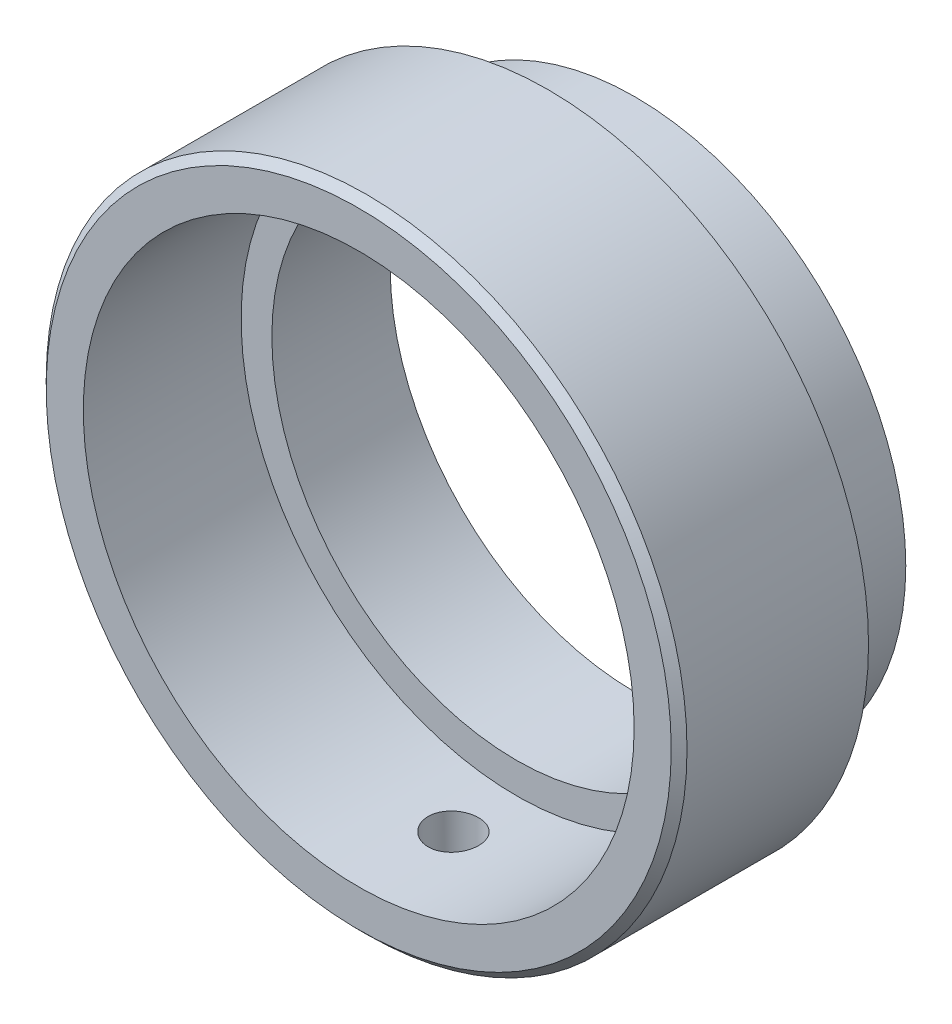
from build123d import *

# Parameters (mm, degrees)
SKETCH2_R          = 1.6
CUT_EXTRUDE1_DEPTH = 25


with BuildPart() as part:
    # Sketch1 → Revolve1 (revolve)
    with BuildSketch(Plane(origin=(0, 0, 0), x_dir=(1, 0, 0), z_dir=(0, 1, 0))):
        Polygon((-17.45, 0), (-19.8, 0), (-20.3, 0.5), (-20.3, 12), (-17.160824742, 12), (-17.160824742, 13.5), (-16.760824742, 13.5), (-16.760824742, 14), (-17.160824742, 14), (-17.160824742, 17.5), (-15.50386168, 17.5), (-15.50386168, 10), (-17.45, 10), align=None)
    revolve(axis=Axis((0, 0, 0), (0, 0, -1)))

    # Sketch2 → Cut-Extrude1 (cut)
    with BuildSketch(Plane(origin=(0, 0, 0), x_dir=(1, 0, 0), z_dir=(0, 1, 0))):
        with Locations((0, 6)):
            Circle(SKETCH2_R)
    extrude(amount=-CUT_EXTRUDE1_DEPTH, mode=Mode.SUBTRACT)


solid = part.part
